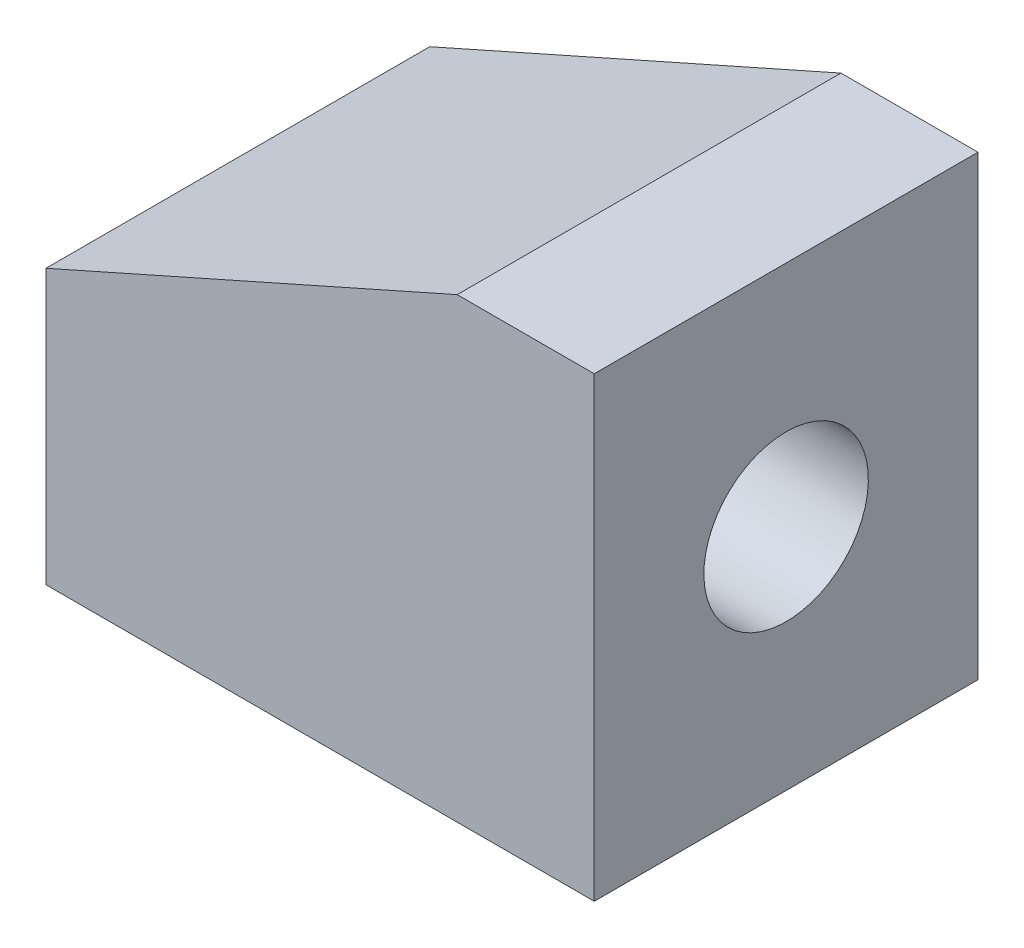
from build123d import *

# Parameters (mm, degrees)
BOSS_EXTRUDE1_DEPTH = 21
SKETCH2_R           = 9
CUT_EXTRUDE1_DEPTH  = 40


with BuildPart() as part:
    # Sketch1 → Boss-Extrude1 (new body, symmetric)
    with BuildSketch(Plane.XY):
        Polygon((0, 0), (-60, 0), (-60, 30), (-15, 50), (0, 50), align=None)
    extrude(amount=BOSS_EXTRUDE1_DEPTH, both=True)

    # Sketch2 → Cut-Extrude1 (cut)
    with BuildSketch(Plane(origin=(0, 0, 0), x_dir=(0, 0, -1), z_dir=(1, 0, 0))):
        with Locations((0, 25)):
            Circle(SKETCH2_R)
    extrude(amount=-CUT_EXTRUDE1_DEPTH, mode=Mode.SUBTRACT)


solid = part.part
